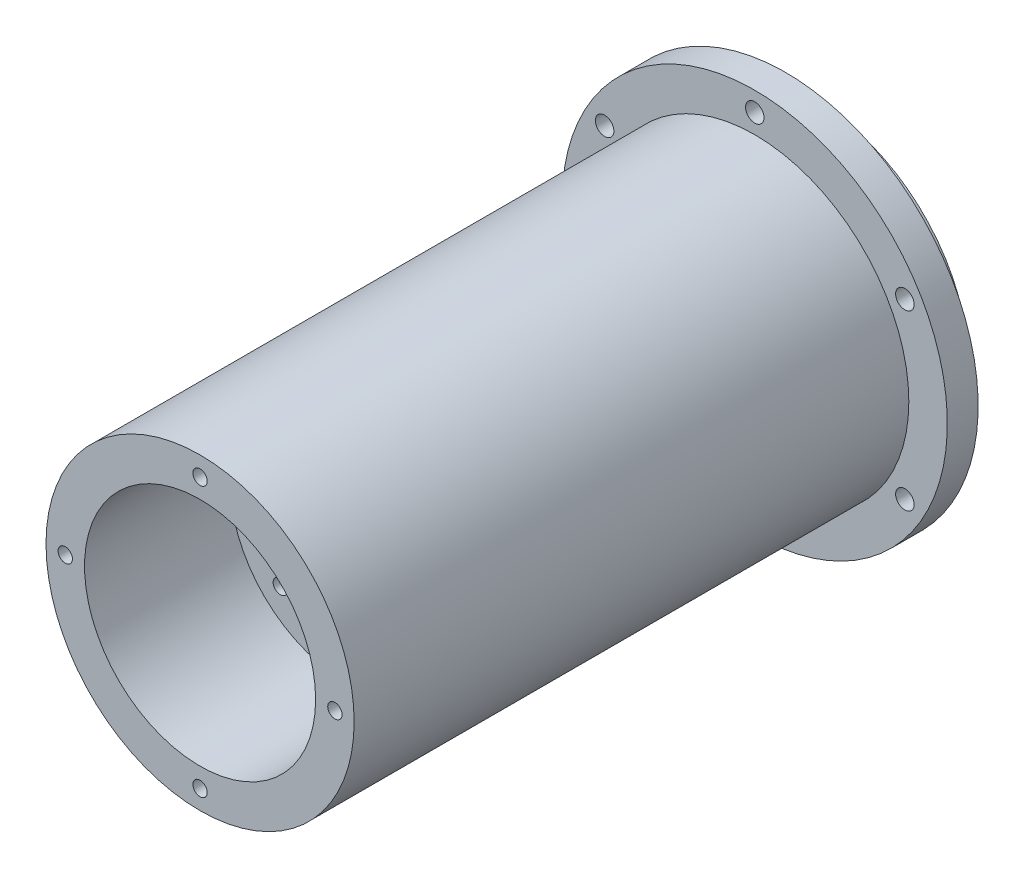
from build123d import *

# Parameters (mm, degrees)
SKETCH1_R           = 31.75
BOSS_EXTRUDE1_DEPTH = 50.8
SKETCH2_R           = 31.75
SKETCH2_R_2         = 25.0825
CUT_EXTRUDE1_DEPTH  = 5.08
SKETCH3_R           = 22.5425
CUT_EXTRUDE2_DEPTH  = 71.247
SKETCH4_R           = 31.75
SKETCH4_R_2         = 25.4
CUT_EXTRUDE3_DEPTH  = 91.44
SKETCH5_R           = 19.05
CUT_EXTRUDE4_DEPTH  = 24.003
SKETCH6_R           = 9.6266
CUT_EXTRUDE5_DEPTH  = 78.597
SKETCH8_R           = 1.524
CUT_EXTRUDE6_DEPTH  = 11.16
CIRPATTERN1_COUNT   = 6
SKETCH9_R           = 1.1811
CUT_EXTRUDE7_DEPTH  = 12.7
CIRPATTERN2_COUNT   = 4
SKETCH10_R          = 11.303
CUT_EXTRUDE8_DEPTH  = 1.397
SKETCH11_R          = 1.1811
CUT_EXTRUDE9_DEPTH  = 78.597
CIRPATTERN3_COUNT   = 4


with BuildPart() as part:
    # Sketch1 → Boss-Extrude1 (new body, symmetric)
    with BuildSketch(Plane.XY):
        Circle(SKETCH1_R)
    extrude(amount=BOSS_EXTRUDE1_DEPTH, both=True)

    # Sketch2 → Cut-Extrude1 (cut)
    with BuildSketch(Plane(origin=(0, 0, -50.8), x_dir=(-1, 0, 0), z_dir=(0, 0, -1))):
        Circle(SKETCH2_R)
        Circle(SKETCH2_R_2, mode=Mode.SUBTRACT)
    extrude(amount=-CUT_EXTRUDE1_DEPTH, mode=Mode.SUBTRACT)

    # Sketch3 → Cut-Extrude2 (cut)
    with BuildSketch(Plane(origin=(0, 0, -50.8), x_dir=(-1, 0, 0), z_dir=(0, 0, -1))):
        Circle(SKETCH3_R)
    extrude(amount=-CUT_EXTRUDE2_DEPTH, mode=Mode.SUBTRACT)

    # Sketch4 → Cut-Extrude3 (cut)
    with BuildSketch(Plane.XY.offset(50.8)):
        Circle(SKETCH4_R)
        Circle(SKETCH4_R_2, mode=Mode.SUBTRACT)
    extrude(amount=-CUT_EXTRUDE3_DEPTH, mode=Mode.SUBTRACT)

    # Sketch5 → Cut-Extrude4 (cut)
    with BuildSketch(Plane.XY.offset(50.8)):
        Circle(SKETCH5_R)
    extrude(amount=-CUT_EXTRUDE4_DEPTH, mode=Mode.SUBTRACT)

    # Sketch6 → Cut-Extrude5 (cut, through all)
    with BuildSketch(Plane.XY.offset(26.797)):
        Circle(SKETCH6_R)
    extrude(amount=-CUT_EXTRUDE5_DEPTH, mode=Mode.SUBTRACT)

    # Sketch8 → Cut-Extrude6 (cut, through all)
    with BuildSketch(Plane.XY.offset(-40.64)):
        with Locations((0, 28.575)):
            Circle(SKETCH8_R)
    cut_extrude6 = extrude(amount=-CUT_EXTRUDE6_DEPTH, mode=Mode.SUBTRACT)

    # CirPattern1: Cut-Extrude6 ×6 about axis
    cirpattern1_axis = Axis((0, 0, 0), (0, 0, 1))
    for i in range(1, CIRPATTERN1_COUNT):
        add(cut_extrude6.rotate(cirpattern1_axis, i * 360 / CIRPATTERN1_COUNT), mode=Mode.SUBTRACT)

    # Sketch9 → Cut-Extrude7 (cut)
    with BuildSketch(Plane.XY.offset(50.8)):
        with Locations((0, 22.225)):
            Circle(SKETCH9_R)
    cut_extrude7 = extrude(amount=-CUT_EXTRUDE7_DEPTH, mode=Mode.SUBTRACT)

    # CirPattern2: Cut-Extrude7 ×4 about axis
    cirpattern2_axis = Axis((0, 0, 0), (0, 0, 1))
    for i in range(1, CIRPATTERN2_COUNT):
        add(cut_extrude7.rotate(cirpattern2_axis, i * 360 / CIRPATTERN2_COUNT), mode=Mode.SUBTRACT)

    # Sketch10 → Cut-Extrude8 (cut)
    with BuildSketch(Plane.XY.offset(26.797)):
        Circle(SKETCH10_R)
    extrude(amount=-CUT_EXTRUDE8_DEPTH, mode=Mode.SUBTRACT)

    # Sketch11 → Cut-Extrude9 (cut, through all)
    with BuildSketch(Plane.XY.offset(26.797)):
        with Locations((-10.776307345, 10.776307345)):
            Circle(SKETCH11_R)
    cut_extrude9 = extrude(amount=-CUT_EXTRUDE9_DEPTH, mode=Mode.SUBTRACT)

    # CirPattern3: Cut-Extrude9 ×4 about axis
    cirpattern3_axis = Axis((0, 0, 0), (0, 0, 1))
    for i in range(1, CIRPATTERN3_COUNT):
        add(cut_extrude9.rotate(cirpattern3_axis, i * 360 / CIRPATTERN3_COUNT), mode=Mode.SUBTRACT)


solid = part.part
